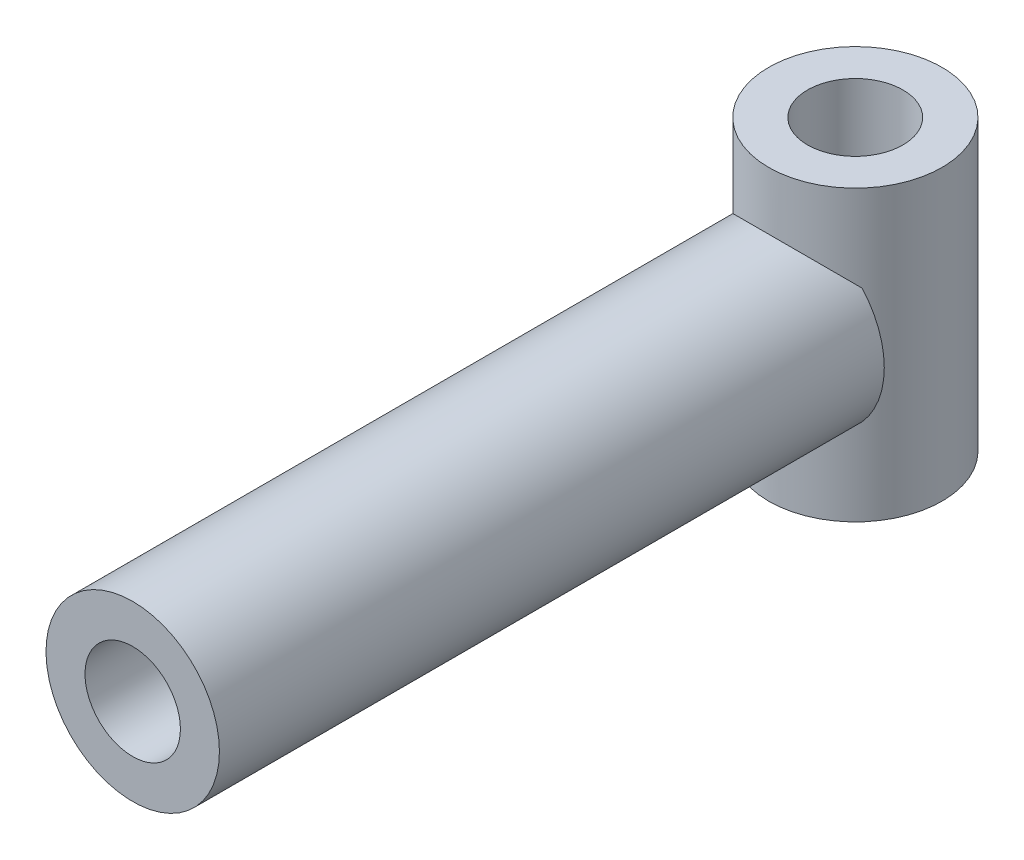
from build123d import *

# Parameters (mm, degrees)
SKICA1_R                 = 3
P_IDAT_VYSUNUT_M1_DEPTH  = 23
SKICA2_R                 = 1.65
ODEBRAT_VYSUNUT_M1_DEPTH = 20
SKICA3_R                 = 3
P_IDAT_VYSUNUT_M2_DEPTH  = 5
SKICA4_R                 = 1.65
ODEBRAT_VYSUNUT_M2_DEPTH = 10


with BuildPart() as part:
    # Skica1 → Přidat vysunutím1 (new body)
    with BuildSketch(Plane.XY):
        Circle(SKICA1_R)
    extrude(amount=P_IDAT_VYSUNUT_M1_DEPTH)

    # Skica2 → Odebrat vysunutím1 (cut)
    with BuildSketch(Plane.XY.offset(23)):
        Circle(SKICA2_R)
    extrude(amount=-ODEBRAT_VYSUNUT_M1_DEPTH, mode=Mode.SUBTRACT)

    # Skica3 → Přidat vysunutím2 (add, symmetric)
    with BuildSketch(Plane(origin=(0, 0, 0), x_dir=(1, 0, 0), z_dir=(0, 1, 0))):
        with Locations((0, 2)):
            Circle(SKICA3_R)
    extrude(amount=P_IDAT_VYSUNUT_M2_DEPTH, both=True)

    # Skica4 → Odebrat vysunutím2 (cut)
    with BuildSketch(Plane(origin=(0, 5, 0), x_dir=(1, 0, 0), z_dir=(0, 1, 0))):
        with Locations((0, 1.995839667)):
            Circle(SKICA4_R)
    extrude(amount=-ODEBRAT_VYSUNUT_M2_DEPTH, mode=Mode.SUBTRACT)


solid = part.part
